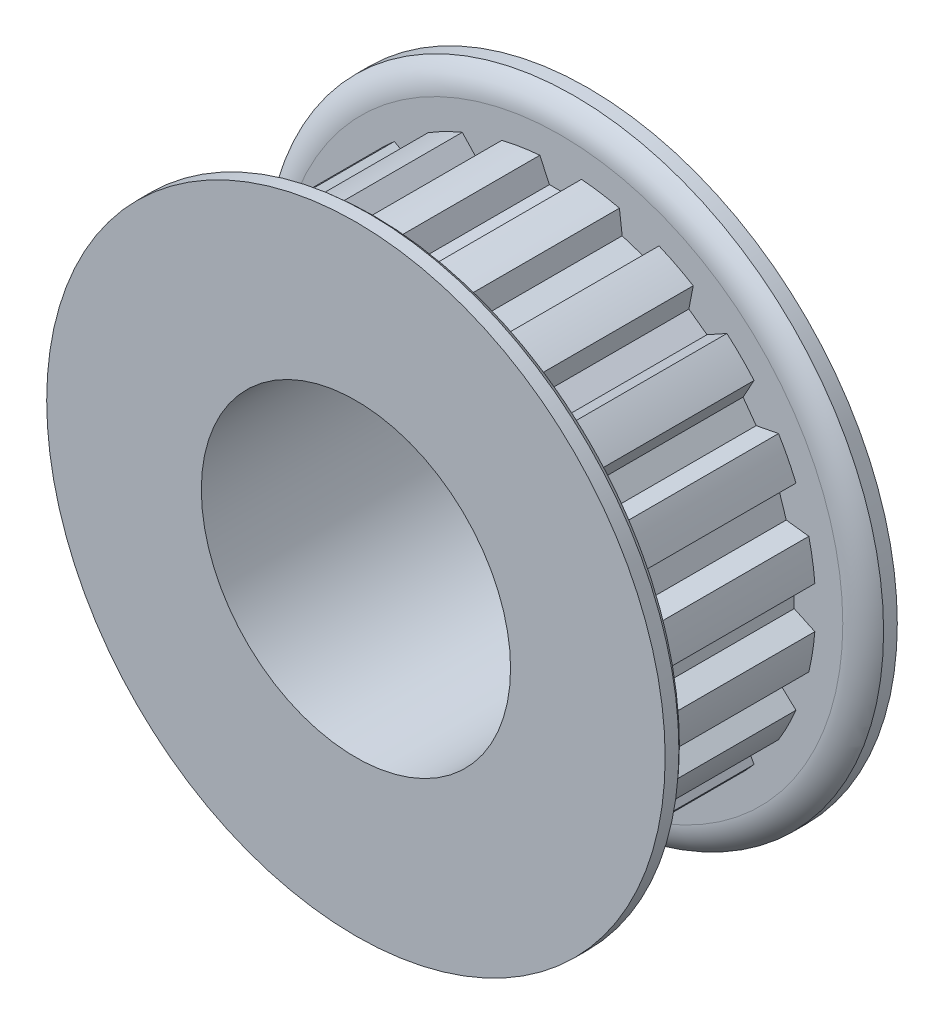
from build123d import *

# Parameters (mm, degrees)
CUT_EXTRUDE1_START = 1.4986
CUT_EXTRUDE1_DEPTH = 10.922
CIRPATTERN1_COUNT  = 20
SKETCH4_R          = 9.525
CUT_EXTRUDE2_DEPTH = 31.500831465


with BuildPart() as part:
    # Sketch2 → Revolve1 (revolve)
    with BuildSketch(Plane(origin=(0, 0, 0), x_dir=(0, 0, -1), z_dir=(1, 0, 0)), mode=Mode.PRIVATE) as revolve1_sk:
        with BuildLine():
            Line((-3.1877, 3.175), (11.1125, 3.175))
            Line((11.1125, 3.175), (11.1125, 19.05))
            Line((11.1125, 19.05), (10.26795, 19.05))
            ThreePointArc((10.26795, 19.05), (9.646555263, 18.316132165), (9.4234, 17.380773865))
            Line((9.4234, 17.380773865), (9.4234, 15.711547731))
            Line((9.4234, 15.711547731), (-1.4986, 15.711547731))
            Line((-1.4986, 15.711547731), (-1.4986, 17.380773865))
            ThreePointArc((-1.4986, 17.380773865), (-1.721755263, 18.316132165), (-2.34315, 19.05))
            Line((-2.34315, 19.05), (-3.1877, 19.05))
            Line((-3.1877, 19.05), (-3.1877, 11.8999))
            Line((-3.1877, 11.8999), (-3.1877, 3.175))
        make_face()
    revolve(revolve1_sk.sketch.rotate(Axis((0, 0, 11.1125), (0, 0, -1)), 90), axis=Axis((0, 0, 11.1125), (0, 0, -1)))

    # Sketch3 → Cut-Extrude1 (cut)
    with BuildSketch(Plane.XY.offset(CUT_EXTRUDE1_START)):
        with BuildLine():
            Line((-0.690489274, 14.3891), (0.690489274, 14.3891))
            Line((0.690489274, 14.3891), (1.2827, 15.6591))
            ThreePointArc((1.2827, 15.6591), (0, 15.711547731), (-1.2827, 15.6591))
            Line((-1.2827, 15.6591), (-0.690489274, 14.3891))
        make_face()
    cut_extrude1 = extrude(amount=-CUT_EXTRUDE1_DEPTH, mode=Mode.SUBTRACT)

    # CirPattern1: Cut-Extrude1 ×20 about axis
    cirpattern1_axis = Axis((0, 0, 0), (0, 0, 1))
    for i in range(1, CIRPATTERN1_COUNT):
        add(cut_extrude1.rotate(cirpattern1_axis, i * 360 / CIRPATTERN1_COUNT), mode=Mode.SUBTRACT)

    # Sketch4 → Cut-Extrude2 (cut, through all)
    with BuildSketch(Plane.XY.offset(3.1877)):
        Circle(SKETCH4_R)
    extrude(amount=-CUT_EXTRUDE2_DEPTH, mode=Mode.SUBTRACT)


solid = part.part
